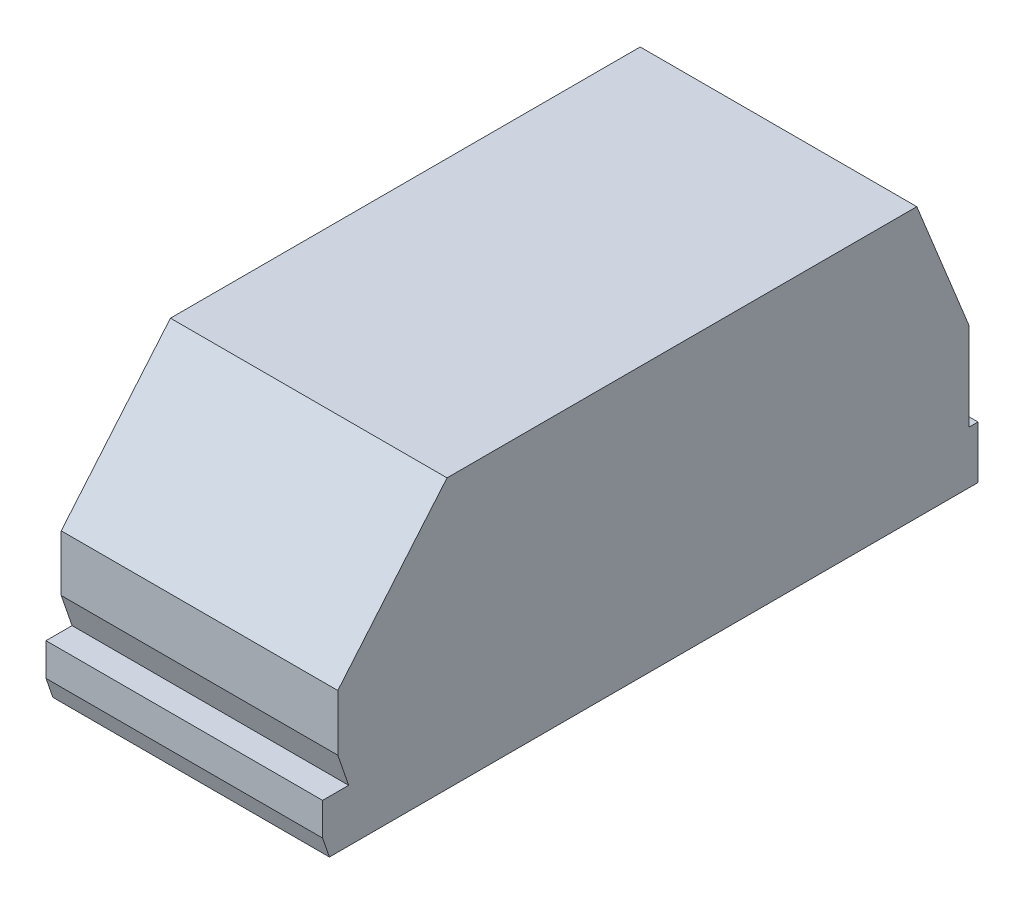
from build123d import *

# Parameters (mm, degrees)
BOSS_EXTRUDE2_DEPTH = 39.5


with BuildPart() as part:
    # Sketch6 → Boss-Extrude2 (new body, symmetric)
    with BuildSketch(Plane(origin=(0, 0, 0), x_dir=(0, 0, -1), z_dir=(1, 0, 0))):
        Polygon((-85.742753648, -14.325502792), (-88.841702167, -5.325502792), (-88.841702167, 10.674497208), (-57.649472482, 47.674497208), (76.526626639, 47.674497208), (88.425634479, 18.292332188), (91.510658272, 10.674497208), (91.510658272, -14.325502792), (94.010658272, -14.325502792), (94.010658272, -29.325502792), (-80.44551992, -29.325502792), (-91.235932802, -29.325502792), (-93.189341728, -23.652391339), (-93.189341728, -14.325502792), align=None)
    extrude(amount=BOSS_EXTRUDE2_DEPTH, both=True)


solid = part.part
